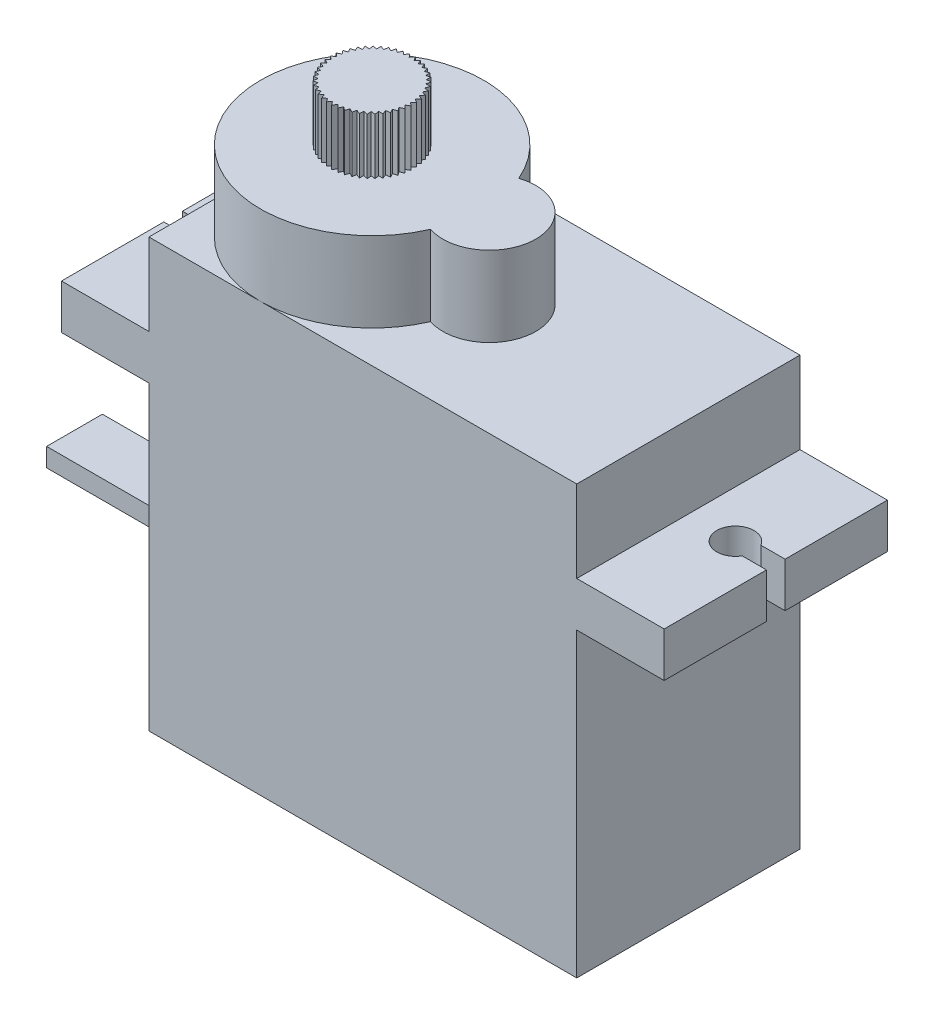
from build123d import *

# Parameters (mm, degrees)
SKETCH2_W           = 23
SKETCH2_H           = 12
BOSS_EXTRUDE1_DEPTH = 23
BOSS_EXTRUDE2_START = -4.4
BOSS_EXTRUDE2_DEPTH = 2.4
SKETCH4_R           = 6
SKETCH4_R_2         = 2.5
BOSS_EXTRUDE3_DEPTH = 4.3
BOSS_EXTRUDE4_DEPTH = 3
SKETCH6_W           = 3
SKETCH6_H           = 1
BOSS_EXTRUDE5_DEPTH = 10


with BuildPart() as part:
    # Sketch2 → Boss-Extrude1 (new body)
    with BuildSketch(Plane(origin=(0, 0, 0), x_dir=(1, 0, 0), z_dir=(0, 1, 0))):
        Rectangle(SKETCH2_W, SKETCH2_H)
    extrude(amount=-BOSS_EXTRUDE1_DEPTH)

    # Sketch3 → Boss-Extrude2 (add)
    with BuildSketch(Plane(origin=(0, 0, 0), x_dir=(1, 0, 0), z_dir=(0, 1, 0)).offset(BOSS_EXTRUDE2_START)):
        with BuildLine():
            Line((-16.2, -0.5), (-16.2, -6))
            Line((-16.2, -6), (-11.5, -6))
            Line((-11.5, -6), (-11.5, 6))
            Line((-11.5, 6), (-16.2, 6))
            Line((-16.2, 6), (-16.2, 0.5))
            Line((-16.2, 0.5), (-15.584293743, 0.5))
            ThreePointArc((-15.584293743, 0.5), (-14.459449294, 0.965925826), (-13.718268339, 0))
            ThreePointArc((-13.718268339, 0), (-14.459449294, -0.965925826), (-15.584293743, -0.5))
            Line((-15.584293743, -0.5), (-16.2, -0.5))
        make_face()
        with BuildLine():
            Line((11.5, 6), (11.5, -6))
            Line((11.5, -6), (16.2, -6))
            Line((16.2, -6), (16.2, -0.5))
            Line((16.2, -0.5), (14.894380034, -0.5))
            ThreePointArc((14.894380034, -0.5), (13.02835463, 0), (14.894380034, 0.5))
            Line((14.894380034, 0.5), (16.2, 0.5))
            Line((16.2, 0.5), (16.2, 6))
            Line((16.2, 6), (11.5, 6))
        make_face()
    extrude(amount=-BOSS_EXTRUDE2_DEPTH)

    # Sketch4 → Boss-Extrude3 (add)
    with BuildSketch(Plane(origin=(0, 0, 0), x_dir=(1, 0, 0), z_dir=(0, 1, 0))):
        with Locations((-5.5, 0)):
            Circle(SKETCH4_R)
        with Locations((0.8, 0)):
            Circle(SKETCH4_R_2)
    extrude(amount=BOSS_EXTRUDE3_DEPTH)

    # Sketch5 → Boss-Extrude4 (add)
    with BuildSketch(Plane(origin=(0, 4.3, 0), x_dir=(1, 0, 0), z_dir=(0, 1, 0))):
        Polygon((-3.255005568, -0.15), (-3.437184296, 0), (-3.255005568, 0.15), (-3.455589794, 0.274946425), (-3.295142762, 0.44844683), (-3.51047784, 0.544986424), (-3.374587739, 0.738324266), (-3.600868956, 0.805301127), (-3.491960749, 1.015026288), (-3.725150111, 1.051245213), (-3.645167266, 1.273615142), (-3.881103504, 1.278429803), (-3.831473318, 1.509476304), (-4.065946143, 1.482800783), (-4.047554268, 1.718400825), (-4.276379508, 1.660711148), (-4.289554146, 1.896660443), (-4.508648409, 1.808986083), (-4.553154459, 2.04107411), (-4.758608002, 1.924979619), (-4.833651254, 2.149064761), (-5.021797754, 2.006621847), (-5.126039057, 2.218705301), (-5.293521035, 2.052455862), (-5.425100203, 2.248752992), (-5.568928939, 2.061663752), (-5.725497937, 2.238671633), (-5.843106805, 2.034081205), (-6.021871655, 2.188641125), (-6.111161921, 1.97020043), (-6.308932561, 2.099554265), (-6.368310838, 1.871161381), (-6.581558046, 1.973000809), (-6.609964728, 1.738731414), (-6.834883102, 1.811239107), (-6.831811271, 1.575273743), (-7.064387138, 1.6171558), (-7.02989161, 1.383705275), (-7.265974648, 1.39421431), (-7.200670997, 1.167444554), (-7.436048299, 1.146393032), (-7.34110187, 0.930350756), (-7.571573122, 0.878114343), (-7.448678237, 0.676654828), (-7.670130674, 0.594165683), (-7.521480394, 0.410883978), (-7.729962192, 0.299614123), (-7.558209186, 0.137780894), (-7.749999982, -0.000284059), (-7.558209186, -0.137780894), (-7.729886469, -0.300177172), (-7.521480394, -0.410883978), (-7.669980579, -0.594713616), (-7.448678237, -0.676654828), (-7.571351335, -0.878637381), (-7.34110187, -0.930350756), (-7.435758777, -1.146881842), (-7.200670997, -1.167444554), (-7.265622557, -1.394660168), (-7.02989161, -1.383705275), (-7.063978761, -1.617550752), (-6.831811271, -1.575273743), (-6.834425728, -1.811576103), (-6.609964728, -1.738731414), (-6.581059835, -1.973273836), (-6.368310838, -1.871161381), (-6.308402404, -2.099758451), (-6.111161921, -1.97020043), (-6.021319013, -2.188772827), (-5.843106805, -2.034081205), (-5.724932672, -2.238728499), (-5.568928939, -2.061663752), (-5.424532402, -2.248734009), (-5.293521035, -2.052455862), (-5.125478853, -2.218610806), (-5.021797754, -2.006621847), (-4.833108643, -2.148896442), (-4.758608002, -1.924979619), (-4.552639125, -2.040834969), (-4.508648409, -1.808986083), (-4.289075284, -1.896354748), (-4.276379508, -1.660711148), (-4.047120423, -1.718034032), (-4.065946143, -1.482800783), (-3.831092233, -1.509054958), (-3.881103504, -1.278429803), (-3.644845742, -1.273146762), (-3.725150111, -1.051245213), (-3.491704522, -1.014519232), (-3.600868956, -0.805301127), (-3.374401382, -0.737787582), (-3.51047784, -0.544986424), (-3.295029601, -0.447890096), (-3.455589794, -0.274946425), align=None)
    extrude(amount=BOSS_EXTRUDE4_DEPTH)

    # Sketch6 → Boss-Extrude5 (add)
    with BuildSketch(Plane.ZY.offset(11.5)):
        with Locations((0, -17.5)):
            Rectangle(SKETCH6_W, SKETCH6_H)
    extrude(amount=BOSS_EXTRUDE5_DEPTH)


solid = part.part
